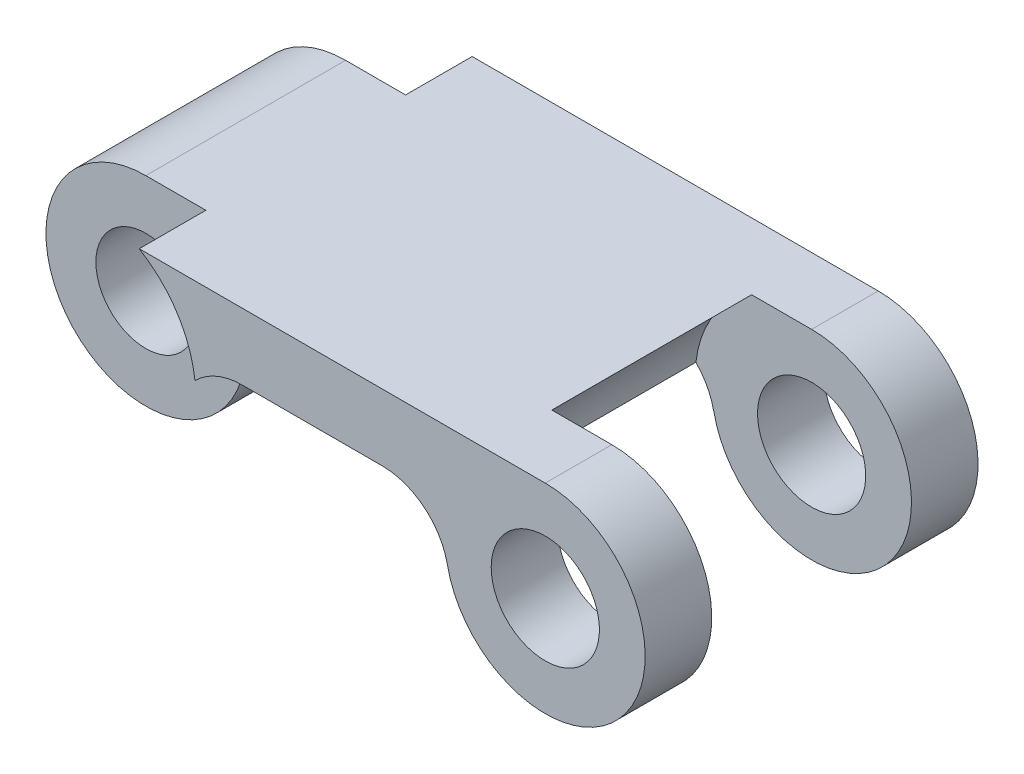
from build123d import *

# Parameters (mm, degrees)
ESTRUSIONE_ESTRUSIONE1_DEPTH = 10
SCHIZZO5_R                   = 1.625
SCHIZZO5_R_2                 = 1.5
TAGLIO_ESTRUSIONE1_DEPTH     = 10
SCHIZZO6_R                   = 3.5
TAGLIO_ESTRUSIONE2_DEPTH     = 2
TAGLIO_ESTRUSIONE3_START     = -8
SCHIZZO6_2_R                 = 3.5
TAGLIO_ESTRUSIONE3_DEPTH     = 12
TAGLIO_ESTRUSIONE4_START     = -2
SCHIZZO7_R                   = 3.5
TAGLIO_ESTRUSIONE4_DEPTH     = 6
RACCORDO1_R                  = 2
RACCORDO2_R                  = 2


with BuildPart() as part:
    # Schizzo1 → Estrusione-Estrusione1 (new body)
    with BuildSketch(Plane.XY):
        with BuildLine():
            Line((-24.824967097, 11.313668705), (-10.824967097, 11.313668705))
            ThreePointArc((-10.824967097, 11.313668705), (-9.092916289, 5.864178962), (-13.653394221, 9.313668705))
            Line((-13.653394221, 9.313668705), (-21.996539972, 9.313668705))
            ThreePointArc((-21.996539972, 9.313668705), (-26.557017904, 5.864178962), (-24.824967097, 11.313668705))
        make_face()
    extrude(amount=ESTRUSIONE_ESTRUSIONE1_DEPTH)

    # Schizzo5 → Taglio-Estrusione1 (cut)
    with BuildSketch(Plane(origin=(0, 0, 0), x_dir=(-1, 0, 0), z_dir=(0, 0, -1))):
        with Locations((10.824967097, 8.313668705)):
            Circle(SCHIZZO5_R)
        with Locations((24.824967097, 8.313668705)):
            Circle(SCHIZZO5_R_2)
    extrude(amount=-TAGLIO_ESTRUSIONE1_DEPTH, mode=Mode.SUBTRACT)

    # Schizzo6 → Taglio-Estrusione2 (cut)
    with BuildSketch(Plane(origin=(0, 0, 0), x_dir=(-1, 0, 0), z_dir=(0, 0, -1))):
        with Locations((24.824967097, 8.313668705)):
            Circle(SCHIZZO6_R)
    extrude(amount=-TAGLIO_ESTRUSIONE2_DEPTH, mode=Mode.SUBTRACT)

    # Schizzo6_2 → Taglio-Estrusione3 (cut)
    with BuildSketch(Plane(origin=(0, 0, 0), x_dir=(-1, 0, 0), z_dir=(0, 0, -1)).offset(TAGLIO_ESTRUSIONE3_START)):
        with Locations((24.824967097, 8.313668705)):
            Circle(SCHIZZO6_2_R)
    extrude(amount=-TAGLIO_ESTRUSIONE3_DEPTH, mode=Mode.SUBTRACT)

    # Schizzo7 → Taglio-Estrusione4 (cut)
    with BuildSketch(Plane(origin=(0, 0, 0), x_dir=(-1, 0, 0), z_dir=(0, 0, -1)).offset(TAGLIO_ESTRUSIONE4_START)):
        with Locations((10.824967097, 8.313668705)):
            Circle(SCHIZZO7_R)
    extrude(amount=-TAGLIO_ESTRUSIONE4_DEPTH, mode=Mode.SUBTRACT)

    # Raccordo1
    raccordo1_edges = [part.edges().sort_by_distance(p)[0] for p in [
        (-21.996539972, 9.313668705, 5),
    ]]
    fillet(raccordo1_edges, radius=RACCORDO1_R)

    # Raccordo2
    raccordo2_edges = [part.edges().sort_by_distance(p)[0] for p in [
        (-13.653394221, 9.313668705, 1),
    ]]
    fillet(raccordo2_edges, radius=RACCORDO2_R)


solid = part.part
